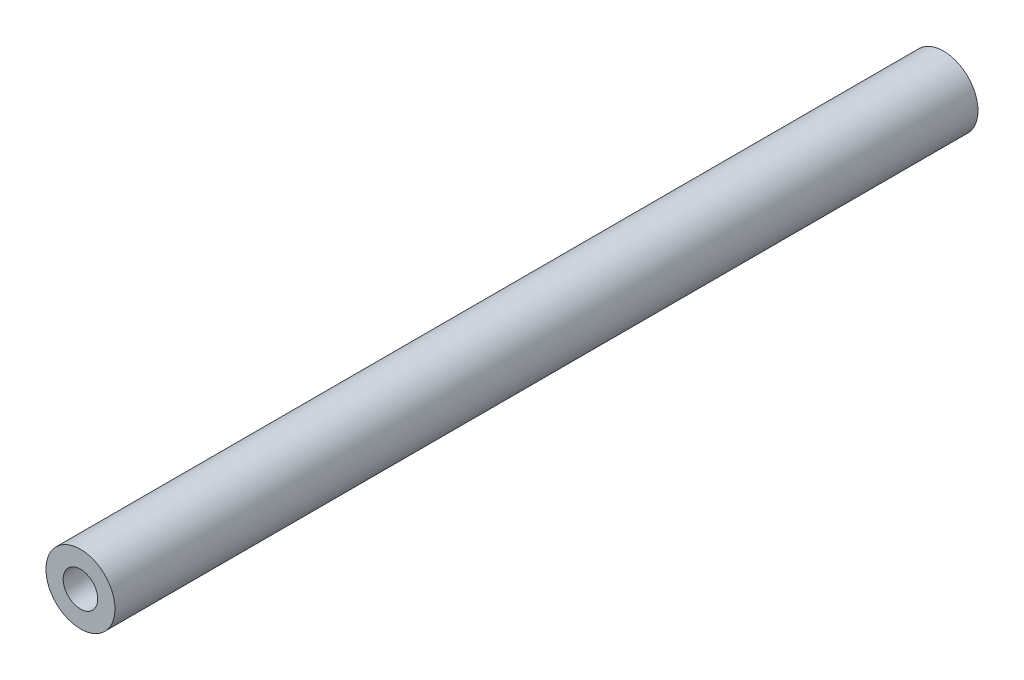
from build123d import *

# Parameters (mm, degrees)
SKETCH1_R           = 2
SKETCH1_R_2         = 1
BOSS_EXTRUDE1_DEPTH = 50


with BuildPart() as part:
    # Sketch1 → Boss-Extrude1 (new body)
    with BuildSketch(Plane.XY):
        Circle(SKETCH1_R)
        Circle(SKETCH1_R_2, mode=Mode.SUBTRACT)
    extrude(amount=BOSS_EXTRUDE1_DEPTH)


solid = part.part
